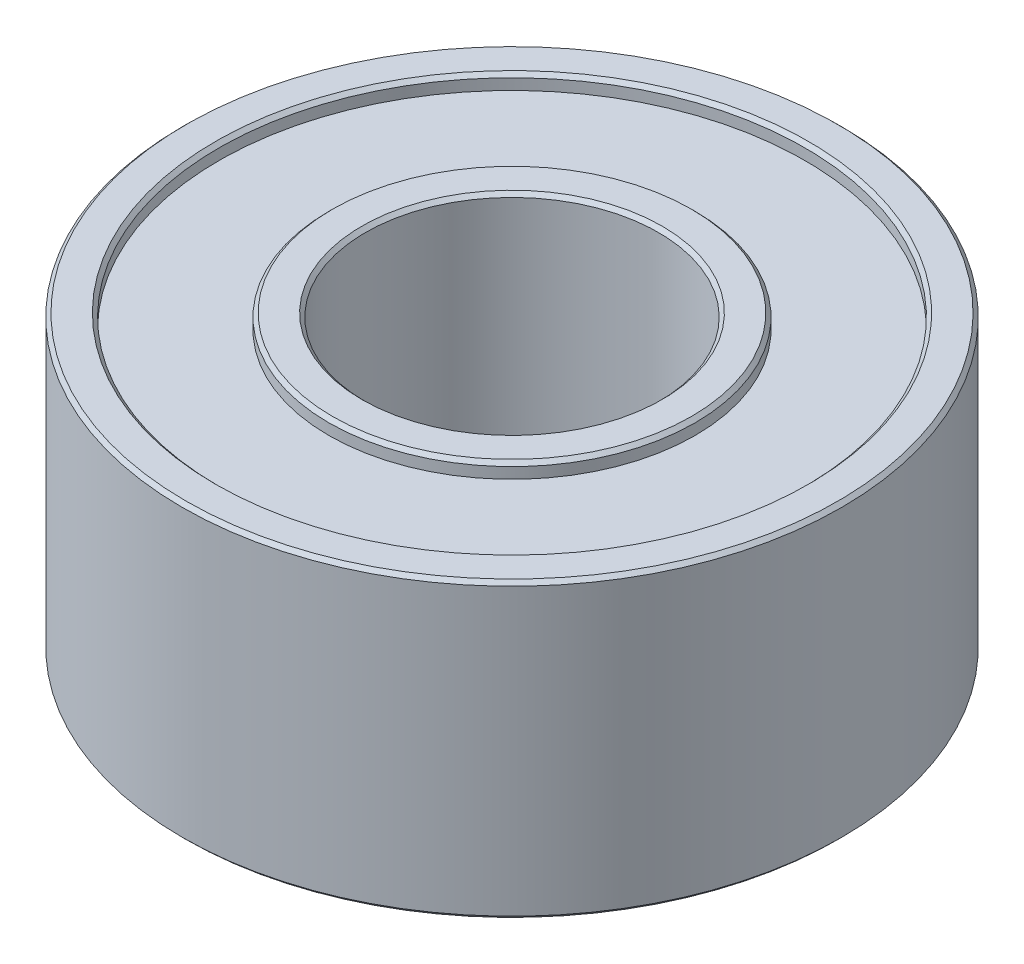
from build123d import *

# Parameters (mm, degrees)
SKETCH1_R           = 4.5
SKETCH1_R_2         = 2
BOSS_EXTRUDE1_DEPTH = 2
CUT_EXTRUDE1_START  = 2
SKETCH2_R           = 4
SKETCH2_R_2         = 2.5
CUT_EXTRUDE1_DEPTH  = 0.2
CUT_EXTRUDE3_START  = -2
SKETCH2_2_R         = 4
SKETCH2_2_R_2       = 2.5
CUT_EXTRUDE3_DEPTH  = 0.2
CHAMFER1_SIZE       = 0.05


with BuildPart() as part:
    # Sketch1 → Boss-Extrude1 (new body, symmetric)
    with BuildSketch(Plane(origin=(0, 0, 0), x_dir=(1, 0, 0), z_dir=(0, 1, 0))):
        Circle(SKETCH1_R)
        Circle(SKETCH1_R_2, mode=Mode.SUBTRACT)
    extrude(amount=BOSS_EXTRUDE1_DEPTH, both=True)

    # Sketch2 → Cut-Extrude1 (cut)
    with BuildSketch(Plane(origin=(0, 0, 0), x_dir=(1, 0, 0), z_dir=(0, 1, 0)).offset(CUT_EXTRUDE1_START)):
        Circle(SKETCH2_R)
        Circle(SKETCH2_R_2, mode=Mode.SUBTRACT)
    extrude(amount=-CUT_EXTRUDE1_DEPTH, mode=Mode.SUBTRACT)

    # Sketch2_2 → Cut-Extrude3 (cut)
    with BuildSketch(Plane(origin=(0, 0, 0), x_dir=(1, 0, 0), z_dir=(0, 1, 0)).offset(CUT_EXTRUDE3_START)):
        Circle(SKETCH2_2_R)
        Circle(SKETCH2_2_R_2, mode=Mode.SUBTRACT)
    extrude(amount=CUT_EXTRUDE3_DEPTH, mode=Mode.SUBTRACT)

    # Chamfer1
    chamfer1_edges = [part.edges().sort_by_distance(p)[0] for p in [
        (-4, 2, 0),
        (-2.5, 2, 0),
        (-2.5, -2, 0),
        (-4, -2, 0),
        (-4.5, -2, 0),
        (-4.5, 2, 0),
        (-2, -2, 0),
        (-2, 2, 0),
    ]]
    chamfer(chamfer1_edges, length=CHAMFER1_SIZE)


solid = part.part
